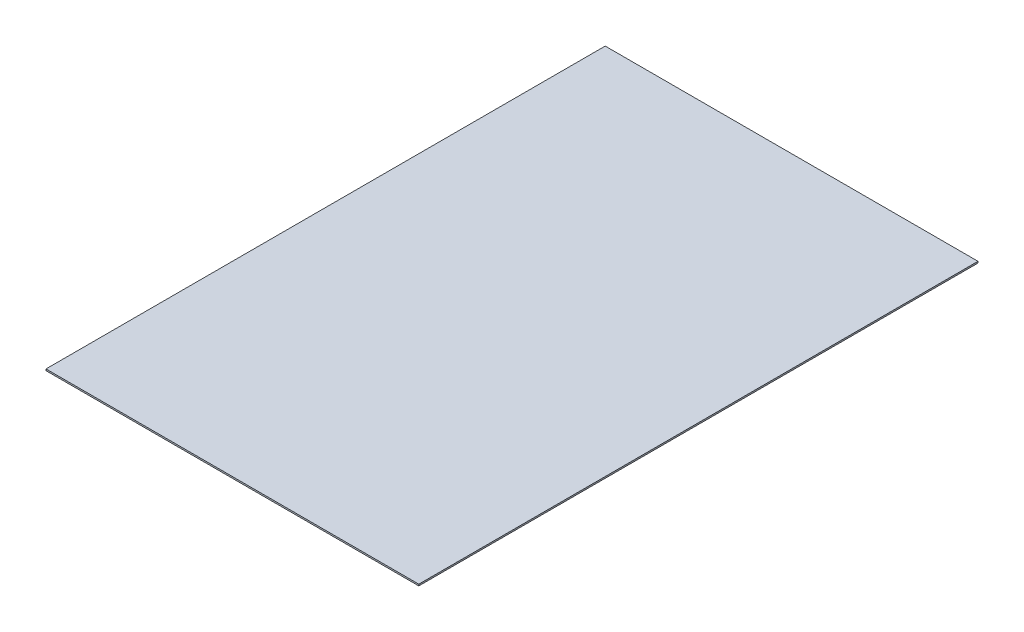
from build123d import *

# Parameters (mm, degrees)
SKETCH1_W           = 762
SKETCH1_H           = 1143
BOSS_EXTRUDE1_DEPTH = 3.175


with BuildPart() as part:
    # Sketch1 → Boss-Extrude1 (new body)
    with BuildSketch(Plane(origin=(0, 0, 0), x_dir=(1, 0, 0), z_dir=(0, 1, 0))):
        Rectangle(SKETCH1_W, SKETCH1_H)
    extrude(amount=BOSS_EXTRUDE1_DEPTH)


solid = part.part
